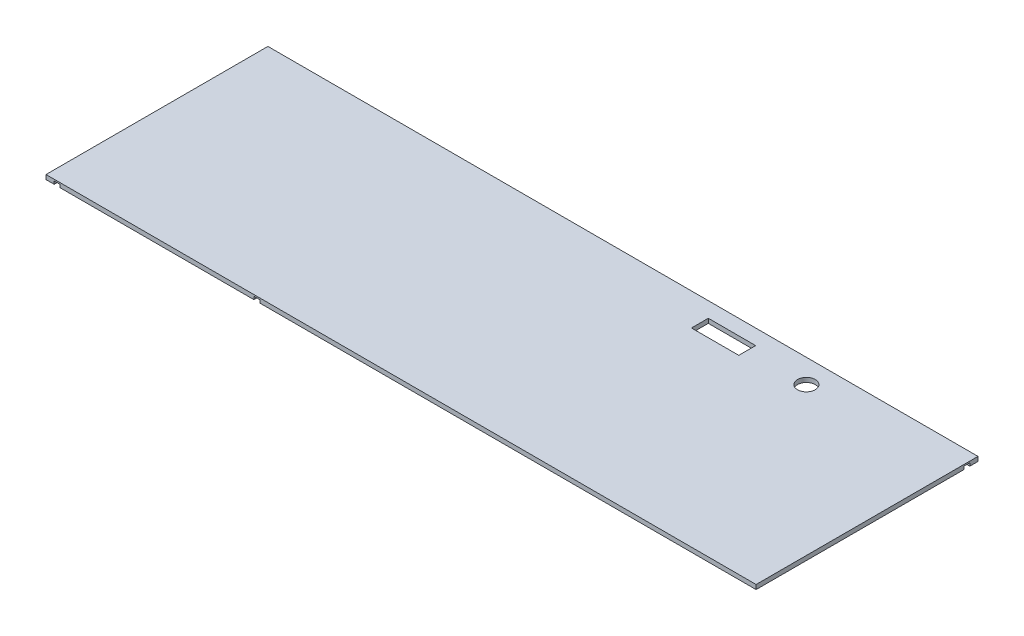
from build123d import *

# Parameters (mm, degrees)
SKETCH1_W           = 2400
SKETCH1_H           = 750
SKETCH1_R           = 30
SKETCH1_W_2         = 160
SKETCH1_H_2         = 57
BOSS_EXTRUDE1_DEPTH = 15
CUT_EXTRUDE1_START  = -75
SKETCH3_W           = 20
SKETCH3_H           = 10
CUT_EXTRUDE1_DEPTH  = 676
CUT_EXTRUDE2_START  = -675
SKETCH4_W           = 20
SKETCH4_H           = 10
CUT_EXTRUDE2_DEPTH  = 600
CUT_EXTRUDE3_START  = -2400
SKETCH4_4_W         = 20
SKETCH4_4_H         = 10
CUT_EXTRUDE3_DEPTH  = 1650
CUT_EXTRUDE4_START  = -2000
SKETCH4_5_W         = 20
SKETCH4_5_H         = 10
CUT_EXTRUDE4_DEPTH  = 1250


with BuildPart() as part:
    # Sketch1 → Boss-Extrude1 (new body)
    with BuildSketch(Plane(origin=(0, 0, 0), x_dir=(1, 0, 0), z_dir=(0, 1, 0))):
        Rectangle(SKETCH1_W, SKETCH1_H)
        with Locations((700, 295)):
            Circle(SKETCH1_R, mode=Mode.SUBTRACT)
        with Locations((420, 295)):
            Rectangle(SKETCH1_W_2, SKETCH1_H_2, mode=Mode.SUBTRACT)
    extrude(amount=BOSS_EXTRUDE1_DEPTH)

    # Sketch3 → Cut-Extrude1 (cut, through all)
    with BuildSketch(Plane(origin=(0, 0, -375), x_dir=(-1, 0, 0), z_dir=(0, 0, -1)).offset(CUT_EXTRUDE1_START)):
        with Locations((1162.5, 5)):
            Rectangle(SKETCH3_W, SKETCH3_H)
        with Locations((487.5, 5)):
            Rectangle(SKETCH3_W, SKETCH3_H)
    extrude(amount=-CUT_EXTRUDE1_DEPTH, mode=Mode.SUBTRACT)

    # Sketch4 → Cut-Extrude2 (cut)
    with BuildSketch(Plane.ZY.offset(1200).offset(CUT_EXTRUDE2_START)):
        with Locations((-337.5, 5)):
            Rectangle(SKETCH4_W, SKETCH4_H)
    extrude(amount=CUT_EXTRUDE2_DEPTH, mode=Mode.SUBTRACT)

    # Sketch4_4 → Cut-Extrude3 (cut)
    with BuildSketch(Plane.ZY.offset(1200).offset(CUT_EXTRUDE3_START)):
        with Locations((-337.5, 5)):
            Rectangle(SKETCH4_4_W, SKETCH4_4_H)
    extrude(amount=CUT_EXTRUDE3_DEPTH, mode=Mode.SUBTRACT)

    # Sketch4_5 → Cut-Extrude4 (cut)
    with BuildSketch(Plane.ZY.offset(1200).offset(CUT_EXTRUDE4_START)):
        with Locations((337.5, 5)):
            Rectangle(SKETCH4_5_W, SKETCH4_5_H)
    extrude(amount=CUT_EXTRUDE4_DEPTH, mode=Mode.SUBTRACT)


solid = part.part
